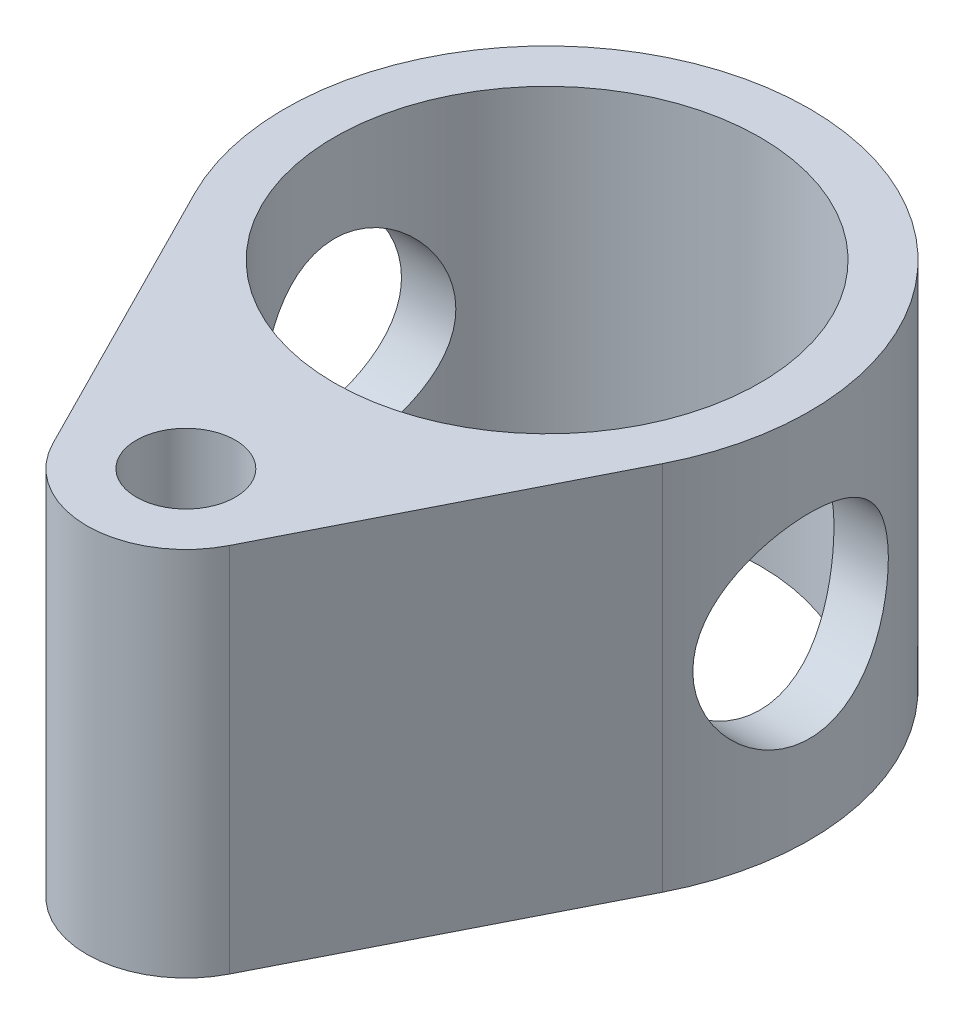
from build123d import *

# Parameters (mm, degrees)
SKETCH1_R           = 10.922
SKETCH1_R_2         = 2.54
BOSS_EXTRUDE1_DEPTH = 12.7
SKETCH2_R           = 10.922
SKETCH2_R_2         = 2.54
BOSS_EXTRUDE2_DEPTH = 6.35
SKETCH3_R           = 5.0165
CUT_EXTRUDE1_DEPTH  = 27.924


with BuildPart() as part:
    # Sketch1 → Boss-Extrude1 (new body)
    with BuildSketch(Plane(origin=(0, 0, 0), x_dir=(1, 0, 0), z_dir=(0, 1, 0))):
        with BuildLine():
            Line((-12.007971664, -6.085561644), (-4.531310062, -20.838438356))
            ThreePointArc((-4.531310062, -20.838438356), (0, -23.622), (4.531310062, -20.838438356))
            Line((4.531310062, -20.838438356), (12.007971664, -6.085561644))
            ThreePointArc((12.007971664, -6.085561644), (0, 13.462), (-12.007971664, -6.085561644))
        make_face()
        Circle(SKETCH1_R, mode=Mode.SUBTRACT)
        with Locations((0, -18.542)):
            Circle(SKETCH1_R_2, mode=Mode.SUBTRACT)
    extrude(amount=BOSS_EXTRUDE1_DEPTH)

    # Sketch2 → Boss-Extrude2 (add)
    with BuildSketch(Plane.XZ):
        with BuildLine():
            Line((-4.531310062, 20.838438356), (-12.007971664, 6.085561644))
            ThreePointArc((-12.007971664, 6.085561644), (0, -13.462), (12.007971664, 6.085561644))
            Line((12.007971664, 6.085561644), (4.531310062, 20.838438356))
            ThreePointArc((4.531310062, 20.838438356), (0, 23.622), (-4.531310062, 20.838438356))
        make_face()
        Circle(SKETCH2_R, mode=Mode.SUBTRACT)
        with Locations((0, 18.542)):
            Circle(SKETCH2_R_2, mode=Mode.SUBTRACT)
        with Locations((0, 18.542)):
            Circle(SKETCH2_R_2)
    extrude(amount=BOSS_EXTRUDE2_DEPTH)

    # Sketch3 → Cut-Extrude1 (cut, through all)
    with BuildSketch(Plane(origin=(13.462, 0, 0), x_dir=(0, 0, -1), z_dir=(1, 0, 0))):
        with Locations((0, 3.175)):
            Circle(SKETCH3_R)
    extrude(amount=-CUT_EXTRUDE1_DEPTH, mode=Mode.SUBTRACT)


solid = part.part
